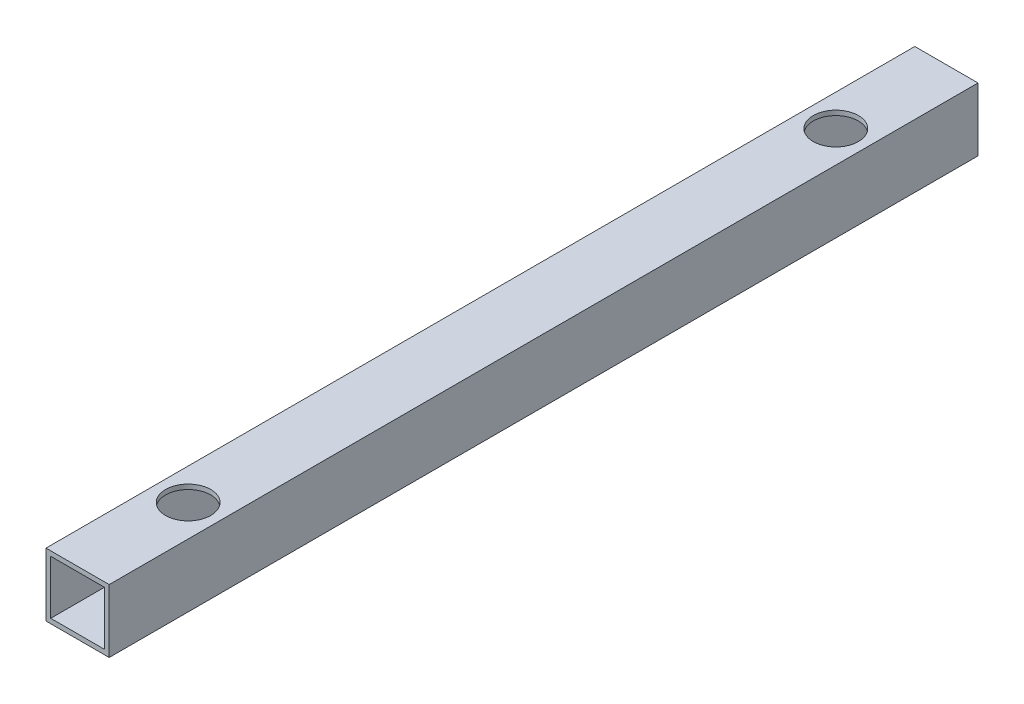
from build123d import *

# Parameters (mm, degrees)
SKETCH6_W           = 40
SKETCH6_H           = 40
SKETCH6_W_2         = 34
SKETCH6_H_2         = 34
BOSS_EXTRUDE2_DEPTH = 550
SKETCH8_R           = 14.3
CUT_EXTRUDE2_DEPTH  = 10000


with BuildPart() as part:
    # Sketch6 → Boss-Extrude2 (new body)
    with BuildSketch(Plane.XY):
        Rectangle(SKETCH6_W, SKETCH6_H)
        Rectangle(SKETCH6_W_2, SKETCH6_H_2, mode=Mode.SUBTRACT)
    extrude(amount=BOSS_EXTRUDE2_DEPTH)

    # Sketch8 → Cut-Extrude2 (cut)
    with BuildSketch(Plane(origin=(0, 20, 0), x_dir=(1, 0, 0), z_dir=(0, 1, 0))):
        with Locations((0, -480)):
            Circle(SKETCH8_R)
        with Locations((0, -70)):
            Circle(SKETCH8_R)
    extrude(amount=-CUT_EXTRUDE2_DEPTH, mode=Mode.SUBTRACT)


solid = part.part
